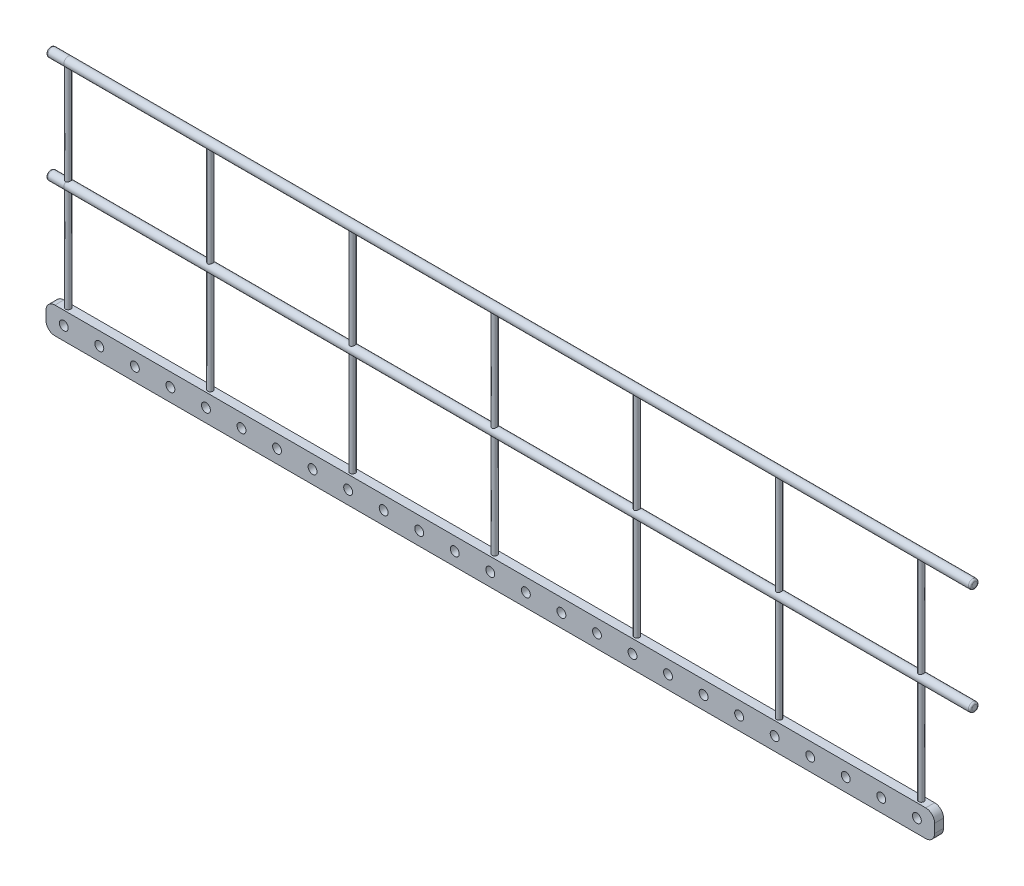
from build123d import *

# Parameters (mm, degrees)
SKETCH2_W                 = 5000
SKETCH2_H                 = 150
BOSS_EXTRUDE1_DEPTH       = 50
FILLET1_R                 = 50
SKETCH3_R                 = 25
CUT_EXTRUDE1_DEPTH        = 51
LPATTERN1_COUNT           = 25
LPATTERN1_PITCH           = 200
SKETCH4_R                 = 15
BOSS_EXTRUDE2_DEPTH       = 600
LPATTERN2_COUNT           = 10
LPATTERN2_PITCH           = 800
SWEEP1_PROFILE_R          = 25
FILLET2_R                 = 10
LPATTERN3_COUNT           = 2
LPATTERN3_PITCH           = 600
LPATTERN3_COPY_1_SKETCH_R = 15
LPATTERN3_COPY_1_DEPTH    = 600
LPATTERN3_COPY_2_SKETCH_R = 15
LPATTERN3_COPY_2_DEPTH    = 600
LPATTERN3_COPY_3_SKETCH_R = 15
LPATTERN3_COPY_3_DEPTH    = 600
LPATTERN3_COPY_4_SKETCH_R = 15
LPATTERN3_COPY_4_DEPTH    = 600
LPATTERN3_COPY_5_SKETCH_R = 15
LPATTERN3_COPY_5_DEPTH    = 600
LPATTERN3_COPY_6_SKETCH_R = 15
LPATTERN3_COPY_6_DEPTH    = 600
FILLET2_OF_LPATTERN3_R    = 10


with BuildPart() as part:
    # Sketch2 → Boss-Extrude1 (new body)
    with BuildSketch(Plane.XY):
        Rectangle(SKETCH2_W, SKETCH2_H)
    extrude(amount=BOSS_EXTRUDE1_DEPTH)

    # Fillet1
    fillet1_edges = [part.edges().sort_by_distance(p)[0] for p in [
        (2500, -75, 25),
        (-2500, -75, 25),
        (-2500, 75, 25),
        (2500, 75, 25),
    ]]
    fillet(fillet1_edges, radius=FILLET1_R)

    # Sketch3 → Cut-Extrude1 (cut, through all)
    with BuildSketch(Plane.XY.offset(50)):
        with Locations((-2400, 0)):
            Circle(SKETCH3_R)
    cut_extrude1 = extrude(amount=-CUT_EXTRUDE1_DEPTH, mode=Mode.SUBTRACT)

    # LPattern1: Cut-Extrude1 ×25
    with Locations(*[(i * LPATTERN1_PITCH, 0, 0) for i in range(1, LPATTERN1_COUNT)]):
        add(cut_extrude1, mode=Mode.SUBTRACT)

    # Sketch4 → Boss-Extrude2 (add)
    with BuildSketch(Plane(origin=(0, 75, 0), x_dir=(1, 0, 0), z_dir=(0, 1, 0))):
        with Locations((-2400, -25)):
            Circle(SKETCH4_R)
    boss_extrude2 = extrude(amount=BOSS_EXTRUDE2_DEPTH)

    # LPattern2: Boss-Extrude2 ×10, 3 skipped
    with Locations(*[(i * LPATTERN2_PITCH, 0, 0) for i in range(1, LPATTERN2_COUNT) if i not in (7, 8, 9)]):
        add(boss_extrude2)

    # Sweep1: sweep along a path in Sketch5
    with BuildLine(Plane(origin=(0, 675, 0), x_dir=(1, 0, 0), z_dir=(0, 1, 0))) as sweep1_path:
        Line((-2500, -25), (-2400, -25))
        Line((-2400, -25), (2700, -25))
    # Sweep1 profile (on start of the path) → Sweep1 (sweep)
    with BuildSketch(Plane(origin=(-2500, 675, 25), x_dir=(0, 0, 1), z_dir=(1, 0, 0))):
        Circle(SWEEP1_PROFILE_R)
    sweep1 = sweep(path=sweep1_path.line)

    # Fillet2
    fillet2_edges = [part.edges().sort_by_distance(p)[0] for p in [
        (2700, 675, 0),
        (-2500, 675, 0),
    ]]
    fillet(fillet2_edges, radius=FILLET2_R)

    # LPattern3: Boss-Extrude2, Sweep1 ×2
    with Locations(*[(0, i * LPATTERN3_PITCH, 0) for i in range(1, LPATTERN3_COUNT)]):
        add(boss_extrude2)
        add(sweep1)

    # LPattern3 copy 1 sketch → LPattern3 copy 1 (add)
    with BuildSketch(Plane(origin=(800, 675, 0), x_dir=(1, 0, 0), z_dir=(0, 1, 0))):
        with Locations((-2400, -25)):
            Circle(LPATTERN3_COPY_1_SKETCH_R)
    extrude(amount=LPATTERN3_COPY_1_DEPTH)

    # LPattern3 copy 2 sketch → LPattern3 copy 2 (add)
    with BuildSketch(Plane(origin=(1600, 675, 0), x_dir=(1, 0, 0), z_dir=(0, 1, 0))):
        with Locations((-2400, -25)):
            Circle(LPATTERN3_COPY_2_SKETCH_R)
    extrude(amount=LPATTERN3_COPY_2_DEPTH)

    # LPattern3 copy 3 sketch → LPattern3 copy 3 (add)
    with BuildSketch(Plane(origin=(2400, 675, 0), x_dir=(1, 0, 0), z_dir=(0, 1, 0))):
        with Locations((-2400, -25)):
            Circle(LPATTERN3_COPY_3_SKETCH_R)
    extrude(amount=LPATTERN3_COPY_3_DEPTH)

    # LPattern3 copy 4 sketch → LPattern3 copy 4 (add)
    with BuildSketch(Plane(origin=(3200, 675, 0), x_dir=(1, 0, 0), z_dir=(0, 1, 0))):
        with Locations((-2400, -25)):
            Circle(LPATTERN3_COPY_4_SKETCH_R)
    extrude(amount=LPATTERN3_COPY_4_DEPTH)

    # LPattern3 copy 5 sketch → LPattern3 copy 5 (add)
    with BuildSketch(Plane(origin=(4000, 675, 0), x_dir=(1, 0, 0), z_dir=(0, 1, 0))):
        with Locations((-2400, -25)):
            Circle(LPATTERN3_COPY_5_SKETCH_R)
    extrude(amount=LPATTERN3_COPY_5_DEPTH)

    # LPattern3 copy 6 sketch → LPattern3 copy 6 (add)
    with BuildSketch(Plane(origin=(4800, 675, 0), x_dir=(1, 0, 0), z_dir=(0, 1, 0))):
        with Locations((-2400, -25)):
            Circle(LPATTERN3_COPY_6_SKETCH_R)
    extrude(amount=LPATTERN3_COPY_6_DEPTH)

    # Fillet2 of LPattern3
    fillet2_of_lpattern3_edges = [part.edges().sort_by_distance(p)[0] for p in [
        (2700, 1275, 0),
        (-2500, 1275, 0),
    ]]
    fillet(fillet2_of_lpattern3_edges, radius=FILLET2_OF_LPATTERN3_R)


solid = part.part
